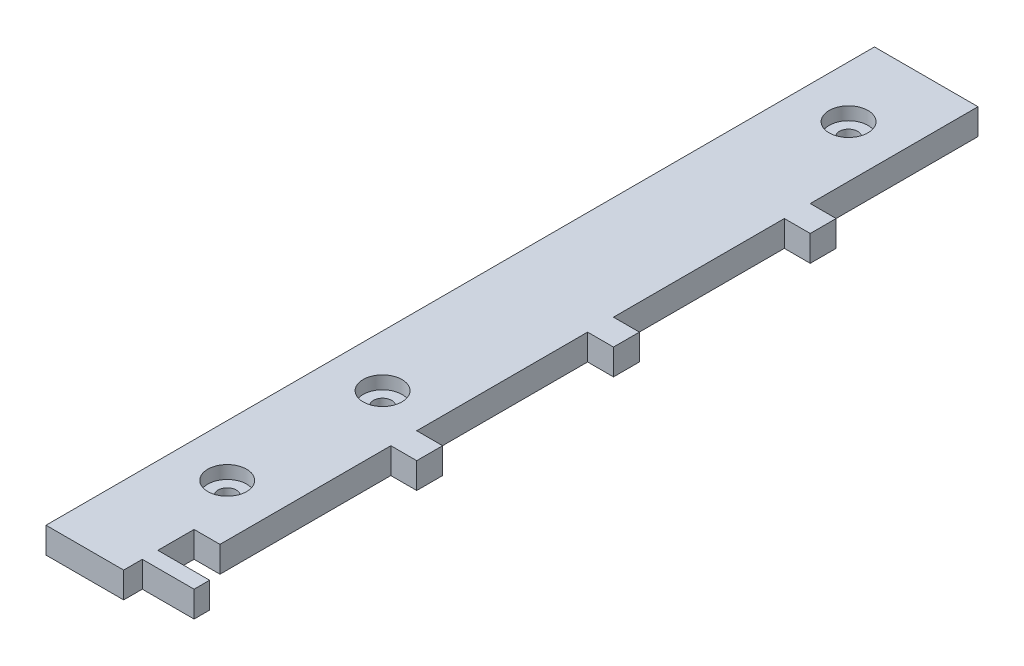
from build123d import *

# Parameters (mm, degrees)
SKETCH1_W                                           = 31.75
SKETCH1_H                                           = 203.2
BOSS_EXTRUDE1_DEPTH                                 = 6.35
SKETCH2_W                                           = 6.35
SKETCH2_H                                           = 41.148
SKETCH2_H_2                                         = 41.91
SKETCH2_W_2                                         = 12.7
SKETCH2_H_3                                         = 4.572
CUT_EXTRUDE1_DEPTH                                  = 7.35
CBORE_FOR_8_BINDING_HEAD_MACHINE_SCREW1_D           = 4.4958
CBORE_FOR_8_BINDING_HEAD_MACHINE_SCREW1_CBORE_D     = 9.525
CBORE_FOR_8_BINDING_HEAD_MACHINE_SCREW1_CBORE_DEPTH = 3.175


with BuildPart() as part:
    # Sketch1 → Boss-Extrude1 (new body)
    with BuildSketch(Plane(origin=(0, 0, 0), x_dir=(1, 0, 0), z_dir=(0, 1, 0))):
        with Locations((15.875, 101.6)):
            Rectangle(SKETCH1_W, SKETCH1_H)
    extrude(amount=BOSS_EXTRUDE1_DEPTH)

    # Sketch2 → Cut-Extrude1 (cut, through all)
    with BuildSketch(Plane(origin=(0, 6.35, 0), x_dir=(1, 0, 0), z_dir=(0, 1, 0))):
        with Locations((28.575, 182.626)):
            Rectangle(SKETCH2_W, SKETCH2_H)
        with Locations((28.575, 134.747)):
            Rectangle(SKETCH2_W, SKETCH2_H_2)
        Polygon((31.75, 59.182), (25.4, 59.182), (25.4, 17.272), (19.05, 17.272), (19.05, 8.382), (31.75, 8.382), align=None)
        with Locations((28.575, 86.487)):
            Rectangle(SKETCH2_W, SKETCH2_H_2)
        with Locations((25.4, 2.286)):
            Rectangle(SKETCH2_W_2, SKETCH2_H_3)
    extrude(amount=-CUT_EXTRUDE1_DEPTH, mode=Mode.SUBTRACT)

    # CBORE for #8 Binding Head Machine Screw1 (through all)
    with Locations(Plane(origin=(0, 6.35, 0), x_dir=(1, 0, 0), z_dir=(0, 1, 0))):
        with Locations((12.7, 31.75), (12.7, 69.85), (12.7, 184.15)):
            CounterBoreHole(CBORE_FOR_8_BINDING_HEAD_MACHINE_SCREW1_D / 2, CBORE_FOR_8_BINDING_HEAD_MACHINE_SCREW1_CBORE_D / 2, CBORE_FOR_8_BINDING_HEAD_MACHINE_SCREW1_CBORE_DEPTH)


solid = part.part
